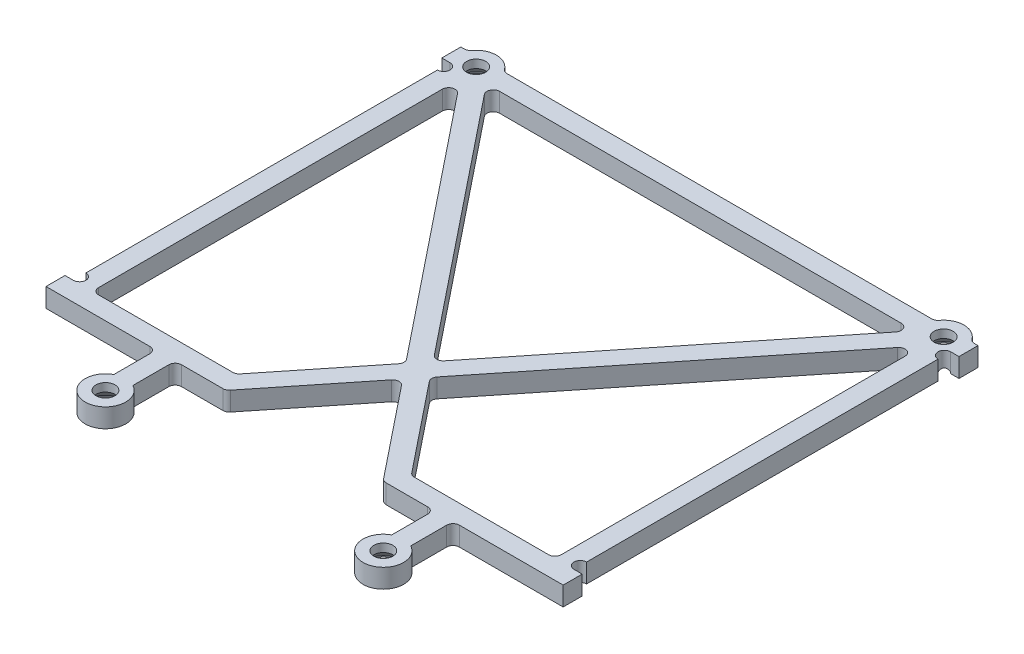
from build123d import *

# Parameters (mm, degrees)
SKETCH1_R                  = 1.5
SHAPE_DEPTH                = 3
MILL_FILLETS_R             = 1
M3_COUNTERSUNKS_AT_2_COUNT = 2
M3_COUNTERSUNKS_AT_2_PITCH = 43.84
M3_COUNTERSUNKS_AT_3_COUNT = 2
M3_COUNTERSUNKS_AT_3_PITCH = 94.086888034
M3_COUNTERSUNKS_AT_4_COUNT = 2
M3_COUNTERSUNKS_AT_4_PITCH = 74.958015582


with BuildPart() as part:
    # Sketch1 → Shape (new body)
    with BuildSketch(Plane(origin=(0, 0, 0), x_dir=(1, 0, 0), z_dir=(0, 1, 0))):
        with BuildLine():
            ThreePointArc((-34.053341195, 38.225), (-36.88, 39.925), (-39.706658805, 38.225))
            Line((-39.706658805, 38.225), (-40.8, 38.225))
            Line((-40.8, 38.225), (-40.8, 35.225))
            Line((-40.8, 35.225), (-39.5, 35.225))
            ThreePointArc((-39.5, 35.225), (-38.5, 34.225), (-39.5, 33.225))
            Line((-39.5, 33.225), (-39.5, -22.225))
            ThreePointArc((-39.5, -22.225), (-38.5, -23.225), (-39.5, -24.225))
            Line((-39.5, -24.225), (-40.8, -24.225))
            Line((-40.8, -24.225), (-40.8, -27.225))
            Line((-40.8, -27.225), (-23.42, -27.225))
            Line((-23.42, -27.225), (-23.42, -33.898341195))
            ThreePointArc((-23.42, -33.898341195), (-21.92, -39.925), (-20.42, -33.898341195))
            Line((-20.42, -33.898341195), (-20.42, -27.225))
            Line((-20.42, -27.225), (-12.393378733, -27.225))
            Line((-12.393378733, -27.225), (0, -11.743815171))
            Line((0, -11.743815171), (12.393378733, -27.225))
            Line((12.393378733, -27.225), (20.42, -27.225))
            Line((20.42, -27.225), (20.42, -33.898341195))
            ThreePointArc((20.42, -33.898341195), (21.92, -39.925), (23.42, -33.898341195))
            Line((23.42, -33.898341195), (23.42, -27.225))
            Line((23.42, -27.225), (40.8, -27.225))
            Line((40.8, -27.225), (40.8, -24.225))
            Line((40.8, -24.225), (39.5, -24.225))
            ThreePointArc((39.5, -24.225), (38.5, -23.225), (39.5, -22.225))
            Line((39.5, -22.225), (39.5, 33.225))
            ThreePointArc((39.5, 33.225), (38.5, 34.225), (39.5, 35.225))
            Line((39.5, 35.225), (40.8, 35.225))
            Line((40.8, 35.225), (40.8, 38.225))
            Line((40.8, 38.225), (39.706658805, 38.225))
            ThreePointArc((39.706658805, 38.225), (36.88, 39.925), (34.053341195, 38.225))
            Line((34.053341195, 38.225), (-34.053341195, 38.225))
        make_face()
        with Locations((36.88, 36.725)):
            Circle(SKETCH1_R, mode=Mode.SUBTRACT)
        Polygon((36.5, -24.225), (13.834640327, -24.225), (1.921447679, -9.343639456), (36.5, 33.850147414), align=None, mode=Mode.SUBTRACT)
        with Locations((-21.92, -36.725)):
            Circle(SKETCH1_R, mode=Mode.SUBTRACT)
        Polygon((-36.5, 33.850147414), (-1.921447679, -9.343639456), (-13.834640327, -24.225), (-36.5, -24.225), align=None, mode=Mode.SUBTRACT)
        with Locations((-36.88, 36.725)):
            Circle(SKETCH1_R, mode=Mode.SUBTRACT)
        Polygon((33.757735438, 35.225), (0, -6.943463741), (-33.757735438, 35.225), align=None, mode=Mode.SUBTRACT)
        with Locations((21.92, -36.725)):
            Circle(SKETCH1_R, mode=Mode.SUBTRACT)
    extrude(amount=SHAPE_DEPTH)

    # Mill fillets
    mill_fillets_edges = [part.edges().sort_by_distance(p)[0] for p in [
        (33.757735438, 1.5, -35.225),
        (-33.757735438, 1.5, -35.225),
        (0, 1.5, 6.943463741),
        (-36.5, 1.5, -33.850147414),
        (-36.5, 1.5, 24.225),
        (-13.834640327, 1.5, 24.225),
        (-1.921447679, 1.5, 9.343639456),
        (36.5, 1.5, -33.850147414),
        (1.921447679, 1.5, 9.343639456),
        (13.834640327, 1.5, 24.225),
        (36.5, 1.5, 24.225),
        (20.42, 1.5, 27.225),
        (12.393378733, 1.5, 27.225),
        (0, 1.5, 11.743815171),
        (-12.393378733, 1.5, 27.225),
        (-20.42, 1.5, 27.225),
        (-23.42, 1.5, 27.225),
        (-39.706658805, 1.5, -38.225),
        (-34.053341195, 1.5, -38.225),
        (34.053341195, 1.5, -38.225),
        (39.706658805, 1.5, -38.225),
        (23.42, 1.5, 27.225),
    ]]
    fillet(mill_fillets_edges, radius=MILL_FILLETS_R)

    # Sketch3 → M3 countersunks (revolve, cut)
    with BuildSketch(Plane(origin=(-21.92, 0, 36.725), x_dir=(0, 0, -1), z_dir=(1, 0, 0))):
        Polygon((0, 0), (0, 3), (1.5, 3), (1.5, 1.7), (3, 0.2), (3, 0), align=None)
    m3_countersunks = revolve(axis=Axis((-21.92, -6.35, 36.725), (0, 1, 0)), mode=Mode.SUBTRACT)

    # M3 countersunks at 2: M3 countersunks ×2
    with Locations(*[(i * M3_COUNTERSUNKS_AT_2_PITCH, 0, 0) for i in range(1, M3_COUNTERSUNKS_AT_2_COUNT)]):
        add(m3_countersunks, mode=Mode.SUBTRACT)

    # M3 countersunks at 3: M3 countersunks ×2
    with Locations(*[Vector(0.624954244, 0, -0.780661382) * (i * M3_COUNTERSUNKS_AT_3_PITCH) for i in range(1, M3_COUNTERSUNKS_AT_3_COUNT)]):
        add(m3_countersunks, mode=Mode.SUBTRACT)

    # M3 countersunks at 4: M3 countersunks ×2
    with Locations(*[Vector(-0.199578389, 0, -0.979881864) * (i * M3_COUNTERSUNKS_AT_4_PITCH) for i in range(1, M3_COUNTERSUNKS_AT_4_COUNT)]):
        add(m3_countersunks, mode=Mode.SUBTRACT)


solid = part.part
